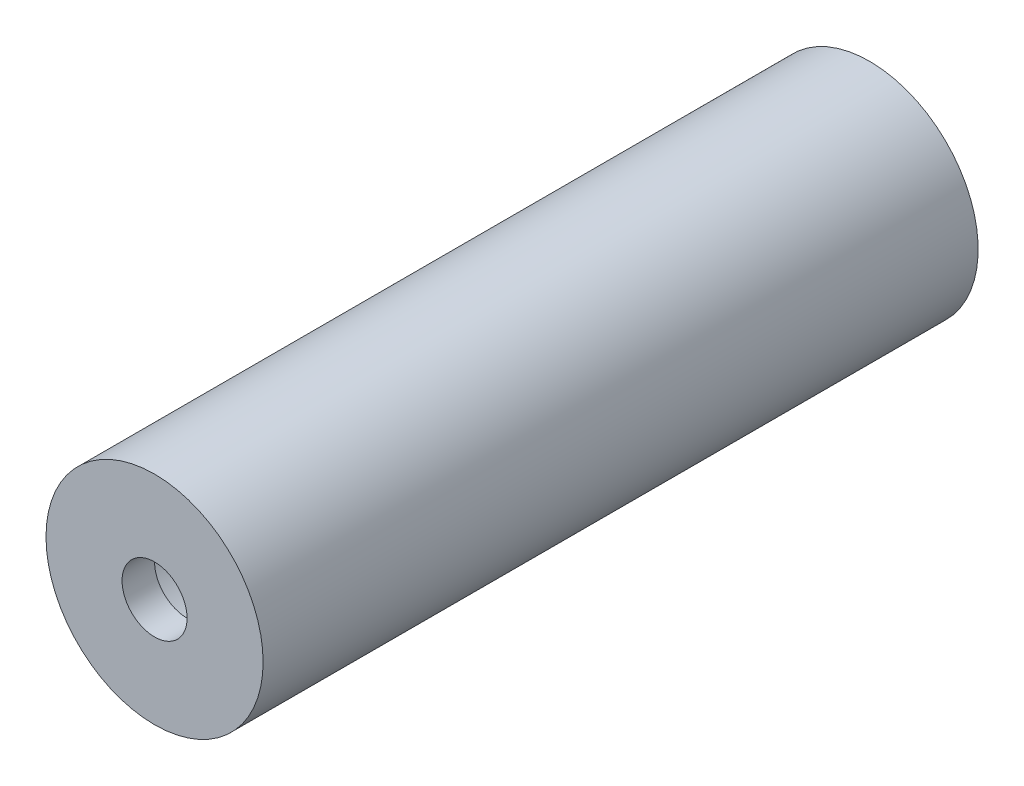
from build123d import *

# Parameters (mm, degrees)
SKETCH2_R           = 16.7
SKETCH2_R_2         = 12.85
BOSS_EXTRUDE1_DEPTH = 100
SKETCH3_R           = 16.7
BOSS_EXTRUDE2_DEPTH = 5
SKETCH4_R           = 16.7
SKETCH4_R_2         = 5
BOSS_EXTRUDE3_DEPTH = 5


with BuildPart() as part:
    # Sketch2 → Boss-Extrude1 (new body)
    with BuildSketch(Plane.XY):
        Circle(SKETCH2_R)
        Circle(SKETCH2_R_2, mode=Mode.SUBTRACT)
    extrude(amount=BOSS_EXTRUDE1_DEPTH)

    # Sketch3 → Boss-Extrude2 (add)
    with BuildSketch(Plane(origin=(0, 0, 0), x_dir=(-1, 0, 0), z_dir=(0, 0, -1))):
        Circle(SKETCH3_R)
    extrude(amount=BOSS_EXTRUDE2_DEPTH)

    # Sketch4 → Boss-Extrude3 (add)
    with BuildSketch(Plane.XY.offset(100)):
        Circle(SKETCH4_R)
        Circle(SKETCH4_R_2, mode=Mode.SUBTRACT)
    extrude(amount=BOSS_EXTRUDE3_DEPTH)


solid = part.part
